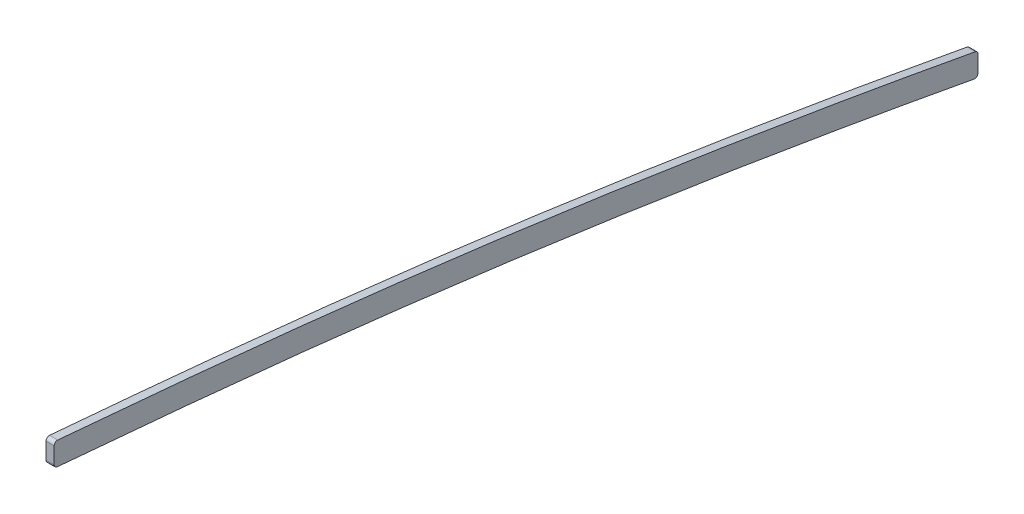
from build123d import *

# Parameters (mm, degrees)
BOSS_EXTRUDE1_DEPTH = 1.5875
FILLET1_R           = 1.27


with BuildPart() as part:
    # Sketch2 → Boss-Extrude1 (new body, symmetric)
    with BuildSketch(Plane(origin=(0, 0, 0), x_dir=(0, 0, -1), z_dir=(1, 0, 0))):
        with BuildLine():
            Line((2311.4, 87.288523189), (2311.4, 78.366424638))
            add(Edge.make_bspline(
                [(2311.4, 78.366424638), (2316.422531269, 77.938965796), (2326.465798303, 77.072769892), (2355.87015988, 74.461943474), (2400.271952644, 70.201698936), (2479.570468264, 61.127378254), (2559.292087872, 49.650907614), (2626.797554585, 38.235484735), (2656.889518578, 32.788503969), (2667.159793662, 30.877771266), (2669.54, 30.432069924)],
                knots=[0.595962005, 0.595962005, 0.595962005, 0.595962005, 0.611587005, 0.627212005, 0.6875, 0.75, 0.875, 0.9375, 0.96241067, 0.969928536, 0.969928536, 0.969928536, 0.969928536], degree=3))
            Line((2669.54, 30.432069924), (2669.54, 39.476142465))
            add(Edge.make_bspline(
                [(2311.4, 87.288523189), (2320.997112773, 86.472755043), (2330.592544535, 85.637637379), (2350.239356518, 83.874334847), (2360.290489794, 82.943307484), (2380.385973971, 81.003183297), (2390.430065378, 79.993418555), (2420.547026195, 76.827577532), (2440.60648589, 74.533672955), (2480.675569568, 69.556278523), (2500.68715183, 66.874150811), (2540.654290207, 61.150246295), (2560.611026428, 58.109755646), (2600.475457131, 51.702465574), (2620.382967089, 48.337538888), (2650.028116889, 43.072156367), (2659.78844051, 41.29687683), (2669.54, 39.476142465)],
                knots=[0.595181211, 0.595181211, 0.595181211, 0.595181211, 0.625, 0.625, 0.65625, 0.65625, 0.6875, 0.6875, 0.75, 0.75, 0.8125, 0.8125, 0.875, 0.875, 0.9375, 0.9375, 0.968210768, 0.968210768, 0.968210768, 0.968210768], degree=3))
        make_face()
    extrude(amount=BOSS_EXTRUDE1_DEPTH, both=True)

    # Fillet1
    fillet1_edges = [part.edges().sort_by_distance(p)[0] for p in [
        (-0.79375, 78.366424638, -2311.4),
        (-0.79375, 87.288523189, -2311.4),
        (-0.79375, 30.432069924, -2669.54),
        (-0.79375, 39.476142465, -2669.54),
    ]]
    fillet(fillet1_edges, radius=FILLET1_R)


solid = part.part
